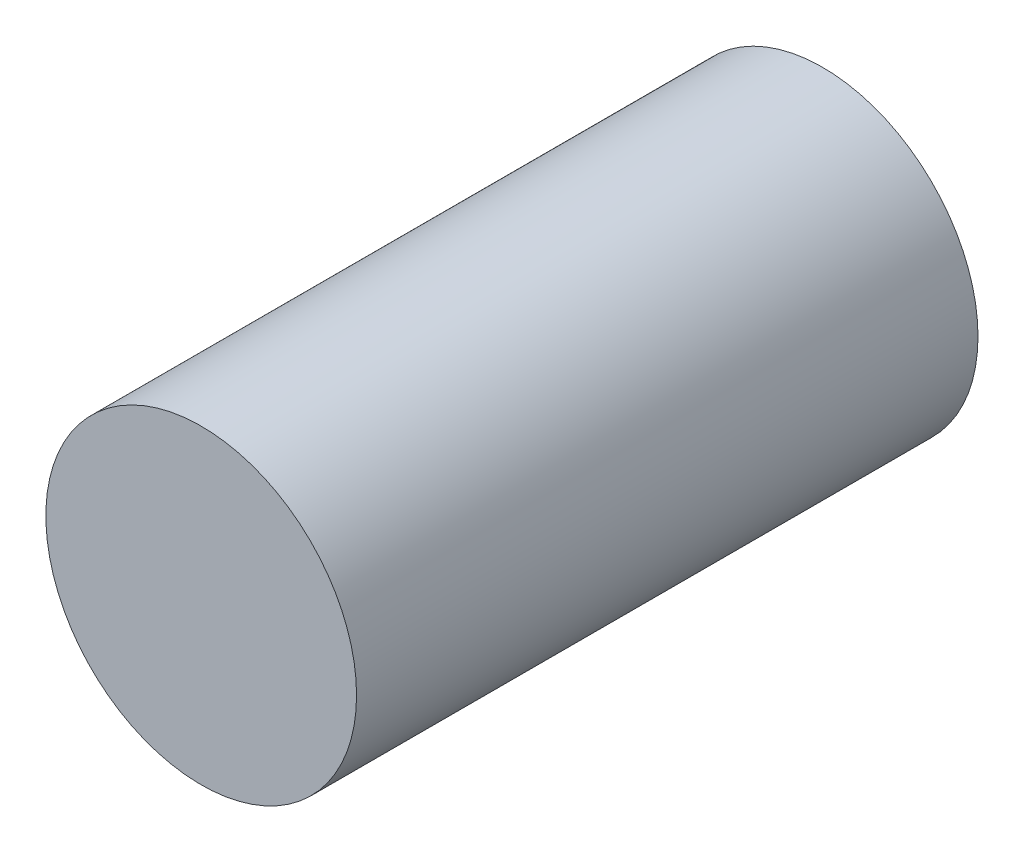
from build123d import *

# Parameters (mm, degrees)
SKETCH1_R      = 63.5
EXTRUDE1_DEPTH = 127


with BuildPart() as part:
    # Sketch1 → Extrude1 (new, symmetric)
    with BuildSketch(Plane.XY):
        Circle(SKETCH1_R)
    extrude(amount=EXTRUDE1_DEPTH, both=True)


solid = part.part
